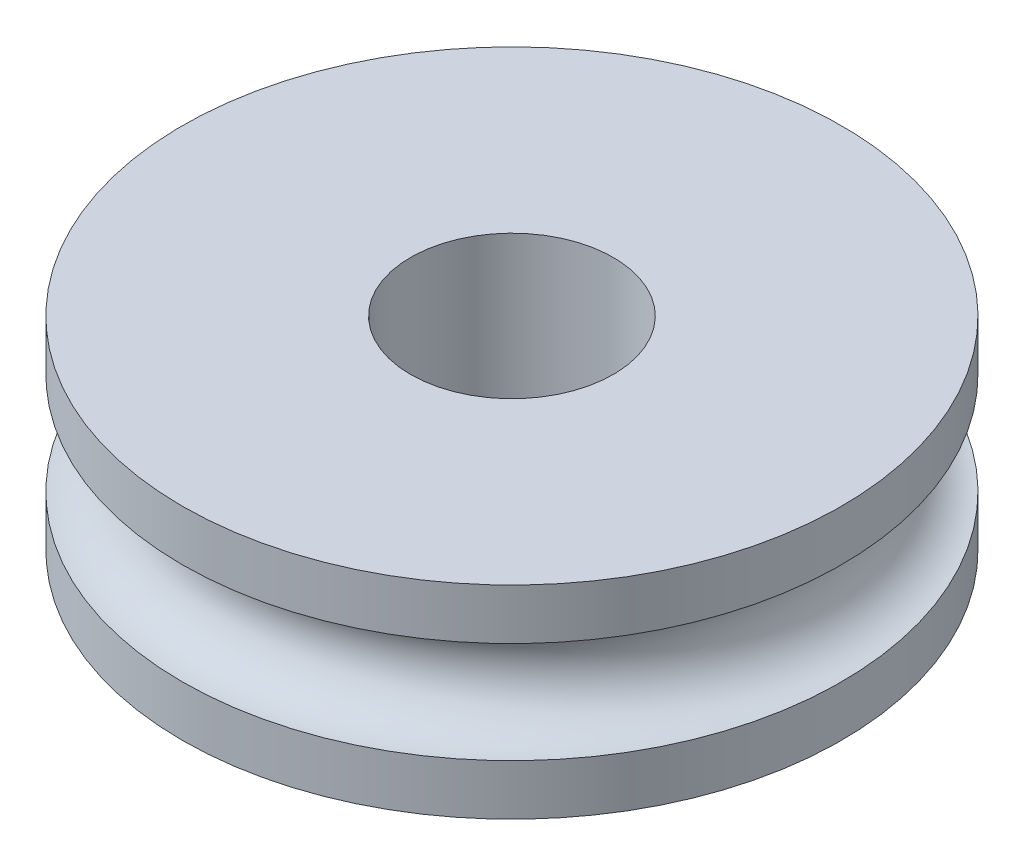
from build123d import *


with BuildPart() as part:
    # Sketch1 → Revolve1 (revolve)
    with BuildSketch(Plane.XY):
        with BuildLine():
            Line((2, 2), (2, -2))
            Line((2, -2), (6.5, -2))
            Line((6.5, -2), (6.5, -1))
            ThreePointArc((6.5, -1), (5.5, 0), (6.5, 1))
            Line((6.5, 1), (6.5, 2))
            Line((6.5, 2), (2, 2))
        make_face()
    revolve(axis=Axis((0, 2, 0), (0, -1, 0)))


solid = part.part
